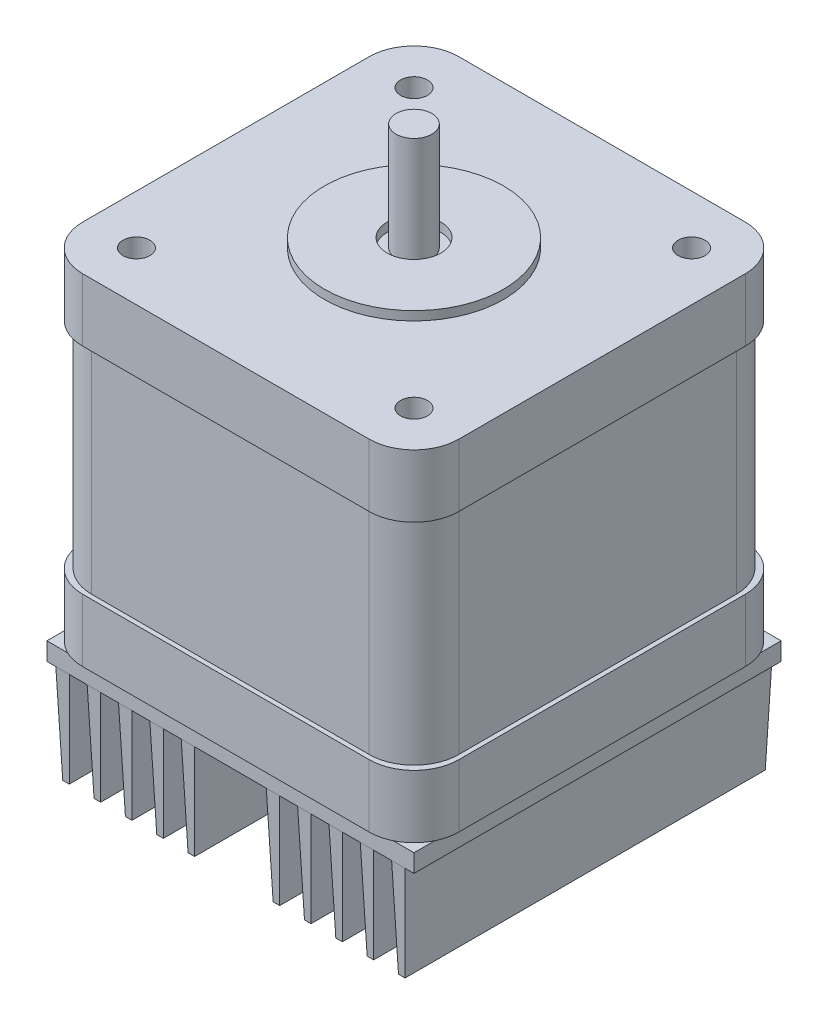
from build123d import *

# Parameters (mm, degrees)
SKETCH1_W       = 42
SKETCH1_H       = 42
EXTRUDE1_DEPTH  = 7
FILLET1_R       = 5
SKETCH2_W       = 41
SKETCH2_H       = 41
EXTRUDE2_DEPTH  = 24
FILLET3_R       = 5
SKETCH3_W       = 42
SKETCH3_H       = 42
EXTRUDE3_DEPTH  = 7
FILLET4_R       = 5
SKETCH4_R       = 10
EXTRUDE4_DEPTH  = 1
SKETCH5_R       = 3
EXTRUDE5_DEPTH  = 1
SKETCH6_R       = 2
EXTRUDE7_DEPTH  = 12
SKETCH7_W       = 20
SKETCH7_H       = 3
EXTRUDE8_DEPTH  = 3
SKETCH8_R       = 1.5
EXTRUDE9_DEPTH  = 10
SKETCH9_W       = 41
SKETCH9_H       = 41
EXTRUDE11_DEPTH = 2
SKETCH10_W      = 1.5
SKETCH10_H      = 41
EXTRUDE12_DEPTH = 11
EXTRUDE12_TAPER = 2


with BuildPart() as part:
    # Sketch1 → Extrude1 (new body)
    with BuildSketch(Plane(origin=(0, 0, 0), x_dir=(1, 0, 0), z_dir=(0, 1, 0))):
        Rectangle(SKETCH1_W, SKETCH1_H)
    extrude(amount=EXTRUDE1_DEPTH)

    # Fillet1
    fillet1_edges = [part.edges().sort_by_distance(p)[0] for p in [
        (21, 3.5, 21),
        (-21, 3.5, 21),
        (-21, 3.5, -21),
        (21, 3.5, -21),
    ]]
    fillet(fillet1_edges, radius=FILLET1_R)



with BuildPart() as body_2:
    # Sketch2 → Extrude2 (new body)
    with BuildSketch(Plane(origin=(0, 7, 0), x_dir=(1, 0, 0), z_dir=(0, 1, 0))):
        Rectangle(SKETCH2_W, SKETCH2_H)
    extrude(amount=EXTRUDE2_DEPTH)

    # Fillet3
    fillet3_edges = [body_2.edges().sort_by_distance(p)[0] for p in [
        (-20.5, 19, -20.5),
        (20.5, 19, -20.5),
        (20.5, 19, 20.5),
        (-20.5, 19, 20.5),
    ]]
    fillet(fillet3_edges, radius=FILLET3_R)


with BuildPart() as body_3:
    # Sketch3 → Extrude3 (new body)
    with BuildSketch(Plane(origin=(0, 31, 0), x_dir=(-1, 0, 0), z_dir=(0, 1, 0))):
        Rectangle(SKETCH3_W, SKETCH3_H)
    extrude(amount=EXTRUDE3_DEPTH)

    # Fillet4
    fillet4_edges = [body_3.edges().sort_by_distance(p)[0] for p in [
        (21, 34.5, 21),
        (-21, 34.5, 21),
        (-21, 34.5, -21),
        (21, 34.5, -21),
    ]]
    fillet(fillet4_edges, radius=FILLET4_R)

    # Sketch4 → Extrude4 (add)
    with BuildSketch(Plane(origin=(0, 38, 0), x_dir=(-1, 0, 0), z_dir=(0, 1, 0))):
        Circle(SKETCH4_R)
    extrude(amount=EXTRUDE4_DEPTH)

    # Sketch5 → Extrude5 (cut)
    with BuildSketch(Plane(origin=(0, 39, 0), x_dir=(-1, 0, 0), z_dir=(0, 1, 0))):
        Circle(SKETCH5_R)
    extrude(amount=-EXTRUDE5_DEPTH, mode=Mode.SUBTRACT)

    # Sketch6 → Extrude7 (add)
    with BuildSketch(Plane(origin=(0, 38, 0), x_dir=(-1, 0, 0), z_dir=(0, 1, 0))):
        Circle(SKETCH6_R)
    extrude(amount=EXTRUDE7_DEPTH)


with BuildPart() as part_1:
    add(part.part)

    add(body_2.part)  # Extrude8 merges body 2
    # Sketch7 → Extrude8 (add)
    with BuildSketch(Plane(origin=(0, 0, -20.5), x_dir=(-1, 0, 0), z_dir=(0, 0, -1))):
        with Locations((0, 8.5)):
            Rectangle(SKETCH7_W, SKETCH7_H)
    extrude(amount=EXTRUDE8_DEPTH)


with BuildPart() as extrude9_tool:
    # Sketch8 → Extrude9 (new body)
    with BuildSketch(Plane(origin=(0, 38, 0), x_dir=(1, 0, 0), z_dir=(0, 1, 0))):
        with Locations((15.5, 15.5)):
            Circle(SKETCH8_R)
        with Locations((-15.5, 15.5)):
            Circle(SKETCH8_R)
        with Locations((-15.5, -15.5)):
            Circle(SKETCH8_R)
        with Locations((15.5, -15.5)):
            Circle(SKETCH8_R)
    extrude(amount=-EXTRUDE9_DEPTH)


with BuildPart() as part_2:
    add(part_1.part)

    # Extrude9: cut by extrude9_tool
    add(extrude9_tool.part, mode=Mode.SUBTRACT)


with BuildPart() as body_3_1:
    add(body_3.part)

    # Extrude9: cut by extrude9_tool
    add(extrude9_tool.part, mode=Mode.SUBTRACT)


with BuildPart() as body_3_2:
    # Sketch9 → Extrude11 (new body)
    with BuildSketch(Plane.XZ):
        Rectangle(SKETCH9_W, SKETCH9_H)
    extrude(amount=EXTRUDE11_DEPTH)

    # Sketch10 → Extrude12 (add)
    with BuildSketch(Plane.XZ.offset(2)):
        with Locations((-18.75, 0)):
            Rectangle(SKETCH10_W, SKETCH10_H)
        with Locations((-15.25, 0)):
            Rectangle(SKETCH10_W, SKETCH10_H)
        with Locations((-11.75, 0)):
            Rectangle(SKETCH10_W, SKETCH10_H)
        with Locations((-8.25, 0)):
            Rectangle(SKETCH10_W, SKETCH10_H)
        with Locations((-4.75, 0)):
            Rectangle(SKETCH10_W, SKETCH10_H)
        with Locations((18.75, 0)):
            Rectangle(SKETCH10_W, SKETCH10_H)
        with Locations((15.25, 0)):
            Rectangle(SKETCH10_W, SKETCH10_H)
        with Locations((11.75, 0)):
            Rectangle(SKETCH10_W, SKETCH10_H)
        with Locations((8.25, 0)):
            Rectangle(SKETCH10_W, SKETCH10_H)
        with Locations((4.75, 0)):
            Rectangle(SKETCH10_W, SKETCH10_H)
    extrude(amount=EXTRUDE12_DEPTH, taper=EXTRUDE12_TAPER)


solid = Compound([part_2.part, body_3_1.part, body_3_2.part])
